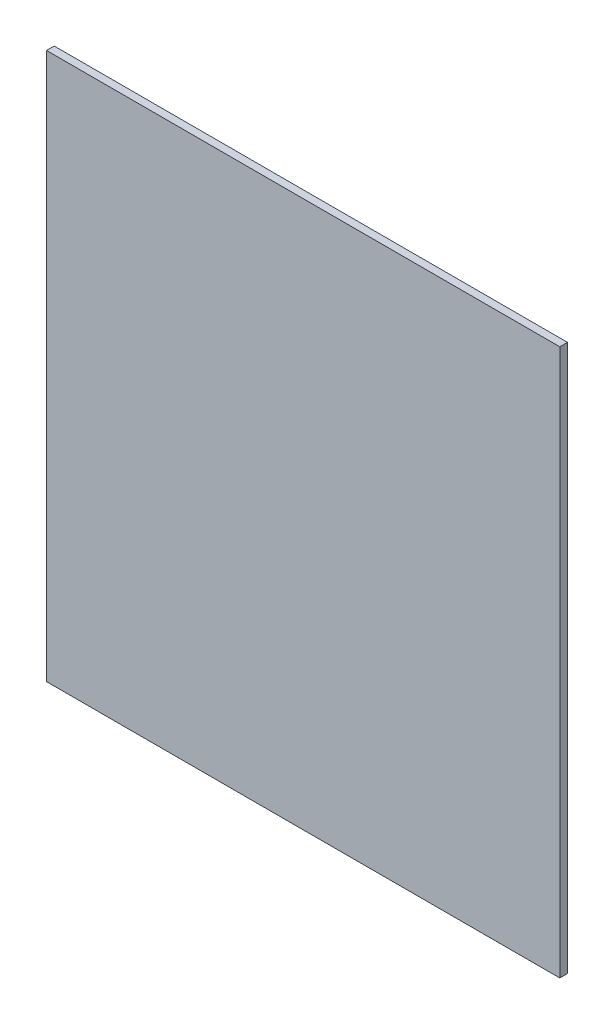
from build123d import *

# Parameters (mm, degrees)
SKETCH1_W           = 200
SKETCH1_H           = 213
BOSS_EXTRUDE1_DEPTH = 3


with BuildPart() as part:
    # Sketch1 → Boss-Extrude1 (new body)
    with BuildSketch(Plane.XY):
        Rectangle(SKETCH1_W, SKETCH1_H)
    extrude(amount=BOSS_EXTRUDE1_DEPTH)


solid = part.part
